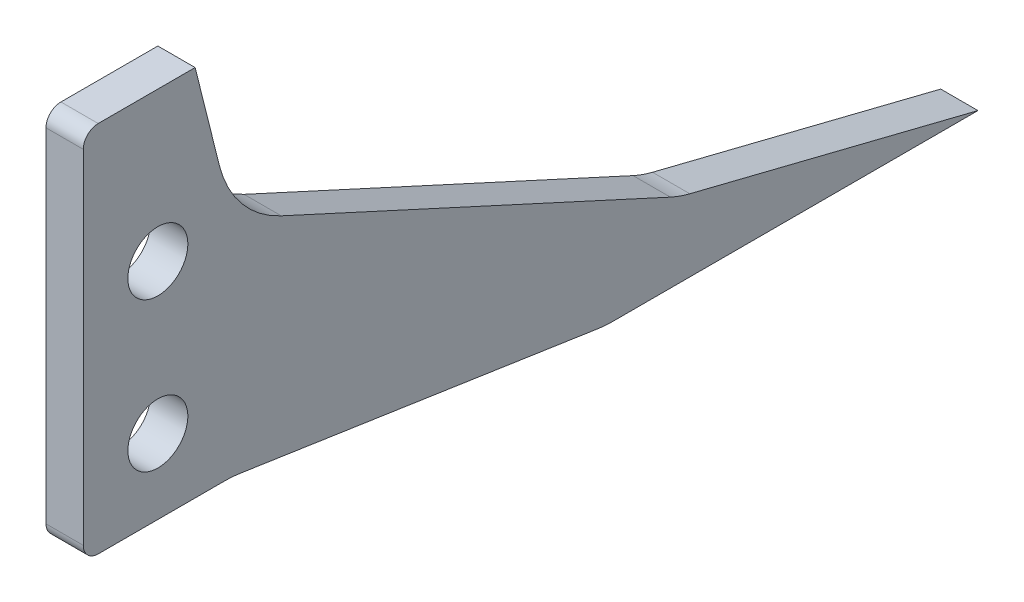
from build123d import *

# Parameters (mm, degrees)
SKETCH3_W                = 114.3
SKETCH3_H                = 88.9
SKETCH3_W_2              = 95.25
SKETCH3_H_2              = 76.2
BOSS_EXTRUDE1_DEPTH      = 12.7
BOSS_EXTRUDE1_DEPTH_BACK = 12.7
SKETCH4_W                = 114.3
SKETCH4_H                = 88.9
BOSS_EXTRUDE2_DEPTH      = 3.175
SKETCH5_W                = 114.3
SKETCH5_H                = 88.9
BOSS_EXTRUDE3_DEPTH      = 3.175
SKETCH7_W                = 41.275
SKETCH7_H                = 25.4
BOSS_EXTRUDE4_DEPTH      = 6.35
SKETCH6_R                = 9.9695
CUT_EXTRUDE1_DEPTH       = 115.3
SKETCH13_W               = 26.035
SKETCH13_H               = 25.4
BOSS_EXTRUDE5_DEPTH      = 4.064
SKETCH19_R               = 0.9525
CUT_EXTRUDE4_DEPTH       = 25.4
SKETCH20_R               = 1.905
CUT_EXTRUDE7_DEPTH       = 3.175
SKETCH23_R               = 5.08
SKETCH23_R_2             = 1.905
SKETCH23_R_3             = 2.38125
CUT_EXTRUDE8_DEPTH       = 3.175
BOSS_EXTRUDE6_DEPTH      = 25.4
BOSS_EXTRUDE7_DEPTH      = 3.175
SKETCH27_R               = 4.7625
CUT_EXTRUDE9_DEPTH       = 32.75
CUT_EXTRUDE9_DEPTH_BACK  = 83.55
SKETCH28_R               = 2.5527
CUT_EXTRUDE10_DEPTH      = 32.75
FILLET1_R                = 9.525
FILLET2_R                = 1.27
CUT_EXTRUDE11_START      = -31.75
SKETCH29_W               = 6.35
SKETCH29_H               = 5.08
CUT_EXTRUDE11_DEPTH      = 38.1


with BuildPart() as part:
    # Sketch3 → Boss-Extrude1 (new body, two sides)
    with BuildSketch(Plane(origin=(0, 0, 0), x_dir=(1, 0, 0), z_dir=(0, 1, 0))) as boss_extrude1_sk:
        with Locations((0, -44.45)):
            Rectangle(SKETCH3_W, SKETCH3_H)
        with Locations((0, -44.45)):
            Rectangle(SKETCH3_W_2, SKETCH3_H_2, mode=Mode.SUBTRACT)
    extrude(amount=BOSS_EXTRUDE1_DEPTH)
    extrude(boss_extrude1_sk.sketch, amount=-BOSS_EXTRUDE1_DEPTH_BACK)

    # Sketch4 → Boss-Extrude2 (add)
    with BuildSketch(Plane.XZ.offset(12.7)):
        with Locations((0, 44.45)):
            Rectangle(SKETCH4_W, SKETCH4_H)
    extrude(amount=BOSS_EXTRUDE2_DEPTH)

    # Sketch7 → Boss-Extrude4 (add)
    with BuildSketch(Plane(origin=(0, -12.7, 0), x_dir=(1, 0, 0), z_dir=(0, 1, 0))):
        with Locations((-26.9875, -50.8)):
            Rectangle(SKETCH7_W, SKETCH7_H)
        with Locations((26.9875, -50.8)):
            Rectangle(SKETCH7_W, SKETCH7_H)
    extrude(amount=BOSS_EXTRUDE4_DEPTH)

    # Sketch6 → Cut-Extrude1 (cut, through all)
    with BuildSketch(Plane.ZY.offset(57.15)):
        with Locations((50.8, 0)):
            Circle(SKETCH6_R)
    extrude(amount=-CUT_EXTRUDE1_DEPTH, mode=Mode.SUBTRACT)

    # Sketch13 → Boss-Extrude5 (add)
    with BuildSketch(Plane(origin=(0, -12.7, 0), x_dir=(1, 0, 0), z_dir=(0, 1, 0))):
        with Locations((-19.3675, -50.8)):
            Rectangle(SKETCH13_W, SKETCH13_H)
        with Locations((19.3675, -50.8)):
            Rectangle(SKETCH13_W, SKETCH13_H)
    extrude(amount=BOSS_EXTRUDE5_DEPTH)

    # Sketch19 → Cut-Extrude4 (cut)
    with BuildSketch(Plane(origin=(0, 12.7, 0), x_dir=(1, 0, 0), z_dir=(0, 1, 0))):
        with Locations((-53.975, -3.175)):
            Circle(SKETCH19_R)
        with Locations((53.975, -3.175)):
            Circle(SKETCH19_R)
        with Locations((-53.975, -85.725)):
            Circle(SKETCH19_R)
        with Locations((53.975, -85.725)):
            Circle(SKETCH19_R)
    extrude(amount=-CUT_EXTRUDE4_DEPTH, mode=Mode.SUBTRACT)

    # Sketch25 → Boss-Extrude6 (add, symmetric)
    with BuildSketch(Plane(origin=(0, 0, 0), x_dir=(0, 0, -1), z_dir=(1, 0, 0))):
        Polygon((0, -15.875), (0, 15.875), (9.525, 15.875), (12.7, 3.175), (12.7, -15.875), align=None)
    extrude(amount=BOSS_EXTRUDE6_DEPTH, both=True)

    # Sketch27 → Cut-Extrude9 (cut, two sides)
    with BuildSketch(Plane(origin=(25.4, 0, 0), x_dir=(0, 0, -1), z_dir=(1, 0, 0))) as cut_extrude9_sk:
        with Locations((6.35, -9.525)):
            Circle(SKETCH27_R)
        with Locations((6.35, 3.175)):
            Circle(SKETCH27_R)
    extrude(amount=CUT_EXTRUDE9_DEPTH, mode=Mode.SUBTRACT)
    extrude(cut_extrude9_sk.sketch, amount=-CUT_EXTRUDE9_DEPTH_BACK, mode=Mode.SUBTRACT)

    # Sketch29 → Cut-Extrude11 (cut)
    with BuildSketch(Plane(origin=(0, 0, 38.1), x_dir=(-1, 0, 0), z_dir=(0, 0, -1)).offset(CUT_EXTRUDE11_START)):
        with Locations((-26.3525, -12.7)):
            Rectangle(SKETCH29_W, SKETCH29_H)
        with Locations((-12.3825, -12.7)):
            Rectangle(SKETCH29_W, SKETCH29_H)
    cut_extrude11 = extrude(amount=CUT_EXTRUDE11_DEPTH, mode=Mode.SUBTRACT)

    # Mirror2: Cut-Extrude11 across plane
    add(cut_extrude11.mirror(Plane(origin=(0, 0, 0), x_dir=(0, 0, 1), z_dir=(1, 0, 0))), mode=Mode.SUBTRACT)


with BuildPart() as body_2:
    # Sketch5 → Boss-Extrude3 (new body)
    with BuildSketch(Plane(origin=(0, 12.7, 0), x_dir=(1, 0, 0), z_dir=(0, 1, 0))):
        with Locations((0, -44.45)):
            Rectangle(SKETCH5_W, SKETCH5_H)
    extrude(amount=BOSS_EXTRUDE3_DEPTH)

    # Sketch20 → Cut-Extrude7 (cut)
    with BuildSketch(Plane(origin=(0, 15.875, 0), x_dir=(1, 0, 0), z_dir=(0, 1, 0))):
        with Locations((-53.975, -3.175)):
            Circle(SKETCH20_R)
        with Locations((-53.975, -85.725)):
            Circle(SKETCH20_R)
        with Locations((53.975, -85.725)):
            Circle(SKETCH20_R)
        with Locations((53.975, -3.175)):
            Circle(SKETCH20_R)
    extrude(amount=-CUT_EXTRUDE7_DEPTH, mode=Mode.SUBTRACT)

    # Sketch23 → Cut-Extrude8 (cut)
    with BuildSketch(Plane(origin=(0, 15.875, 0), x_dir=(1, 0, 0), z_dir=(0, 1, 0))):
        with Locations((36.232509154, -69.504266718)):
            Circle(SKETCH23_R)
        with Locations((44.45, -62.808533435)):
            Circle(SKETCH23_R_2)
        with Locations((28.015018307, -76.2)):
            Circle(SKETCH23_R_2)
        with Locations((2.615018307, -60.427283435)):
            Circle(SKETCH23_R_3)
    extrude(amount=-CUT_EXTRUDE8_DEPTH, mode=Mode.SUBTRACT)


with BuildPart() as body_3:
    # Sketch26 → Boss-Extrude7 (new body)
    with BuildSketch(Plane(origin=(25.4, 0, 0), x_dir=(0, 0, -1), z_dir=(1, 0, 0))):
        Polygon((0, 15.875), (9.525, 15.875), (12.7, 3.175), (50.8, -14.2875), (76.2, -20.6375), (44.45, -20.6375), (12.7, -15.875), (0, -15.875), align=None)
    extrude(amount=BOSS_EXTRUDE7_DEPTH)

    # Sketch28 → Cut-Extrude10 (cut, through all)
    with BuildSketch(Plane.ZY.offset(-25.4)):
        with Locations((-6.35, 3.175)):
            Circle(SKETCH28_R)
        with Locations((-6.35, -9.525)):
            Circle(SKETCH28_R)
    extrude(amount=-CUT_EXTRUDE10_DEPTH, mode=Mode.SUBTRACT)

    # Fillet1
    fillet1_edges = [body_3.edges().sort_by_distance(p)[0] for p in [
        (26.9875, 3.175, -12.7),
        (26.9875, -14.2875, -50.8),
        (26.9875, -20.6375, -44.45),
        (26.9875, -15.875, -12.7),
    ]]
    fillet(fillet1_edges, radius=FILLET1_R)

    # Fillet2
    fillet2_edges = [body_3.edges().sort_by_distance(p)[0] for p in [
        (26.9875, 15.875, 0),
        (26.9875, -15.875, 0),
    ]]
    fillet(fillet2_edges, radius=FILLET2_R)


with BuildPart() as body_4:
    # Mirror1: mirrored copy
    add(body_3.part.mirror(Plane(origin=(0, 0, 0), x_dir=(0, 0, 1), z_dir=(1, 0, 0))))


solid = body_3.part
